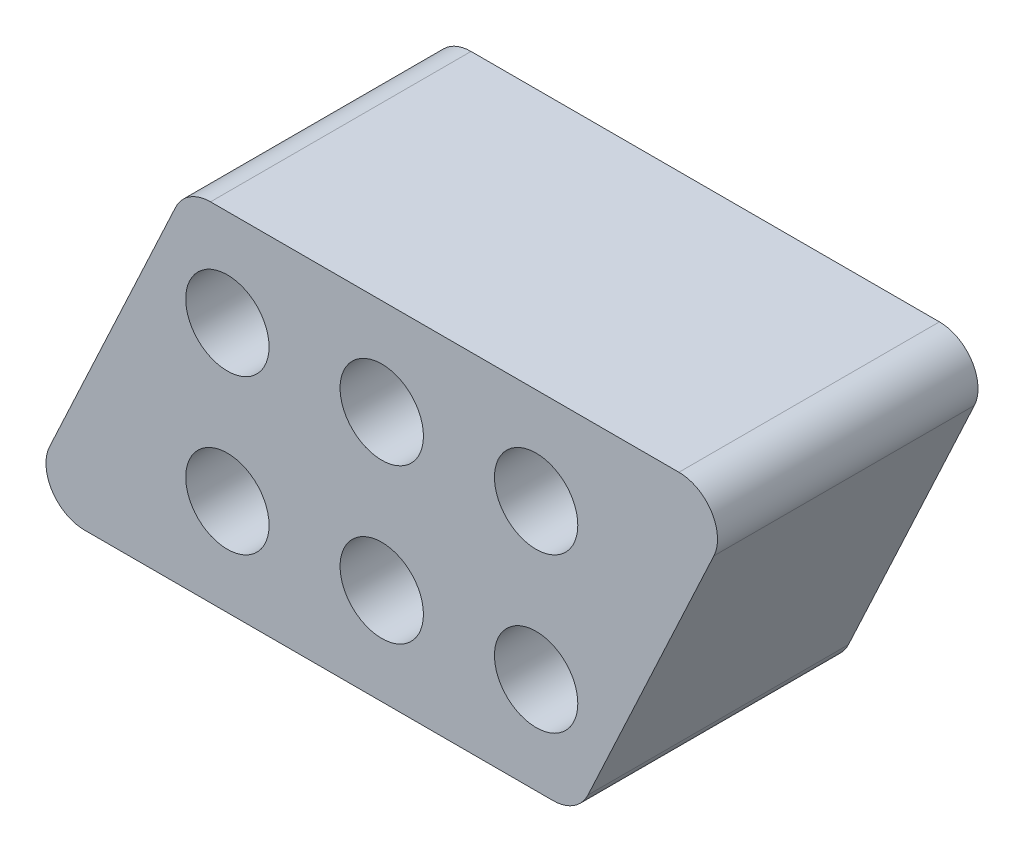
from build123d import *

# Parameters (mm, degrees)
SKETCH1_R           = 3.429
BOSS_EXTRUDE1_DEPTH = 21.43125


with BuildPart() as part:
    # Sketch1 → Boss-Extrude1 (new body)
    with BuildSketch(Plane.XY):
        with BuildLine():
            Line((-24.449580761, -14.2875), (14.085893059, -14.2875))
            ThreePointArc((14.085893059, -14.2875), (15.791819315, -13.79026784), (16.963420282, -12.454312981))
            Line((16.963420282, -12.454312981), (27.327107985, 9.770687019))
            ThreePointArc((27.327107985, 9.770687019), (27.127348602, 12.818426257), (24.449580761, 14.2875))
            Line((24.449580761, 14.2875), (-14.085893059, 14.2875))
            ThreePointArc((-14.085893059, 14.2875), (-15.791819315, 13.79026784), (-16.963420282, 12.454312981))
            Line((-16.963420282, 12.454312981), (-27.327107985, -9.770687019))
            ThreePointArc((-27.327107985, -9.770687019), (-27.127348602, -12.818426257), (-24.449580761, -14.2875))
        make_face()
        with Locations((-12.7, -6.35)):
            Circle(SKETCH1_R, mode=Mode.SUBTRACT)
        with Locations((0, -6.35)):
            Circle(SKETCH1_R, mode=Mode.SUBTRACT)
        with Locations((12.7, -6.35)):
            Circle(SKETCH1_R, mode=Mode.SUBTRACT)
        with Locations((0, 6.35)):
            Circle(SKETCH1_R, mode=Mode.SUBTRACT)
        with Locations((12.7, 6.35)):
            Circle(SKETCH1_R, mode=Mode.SUBTRACT)
        with Locations((-12.7, 6.35)):
            Circle(SKETCH1_R, mode=Mode.SUBTRACT)
    extrude(amount=BOSS_EXTRUDE1_DEPTH)


solid = part.part
